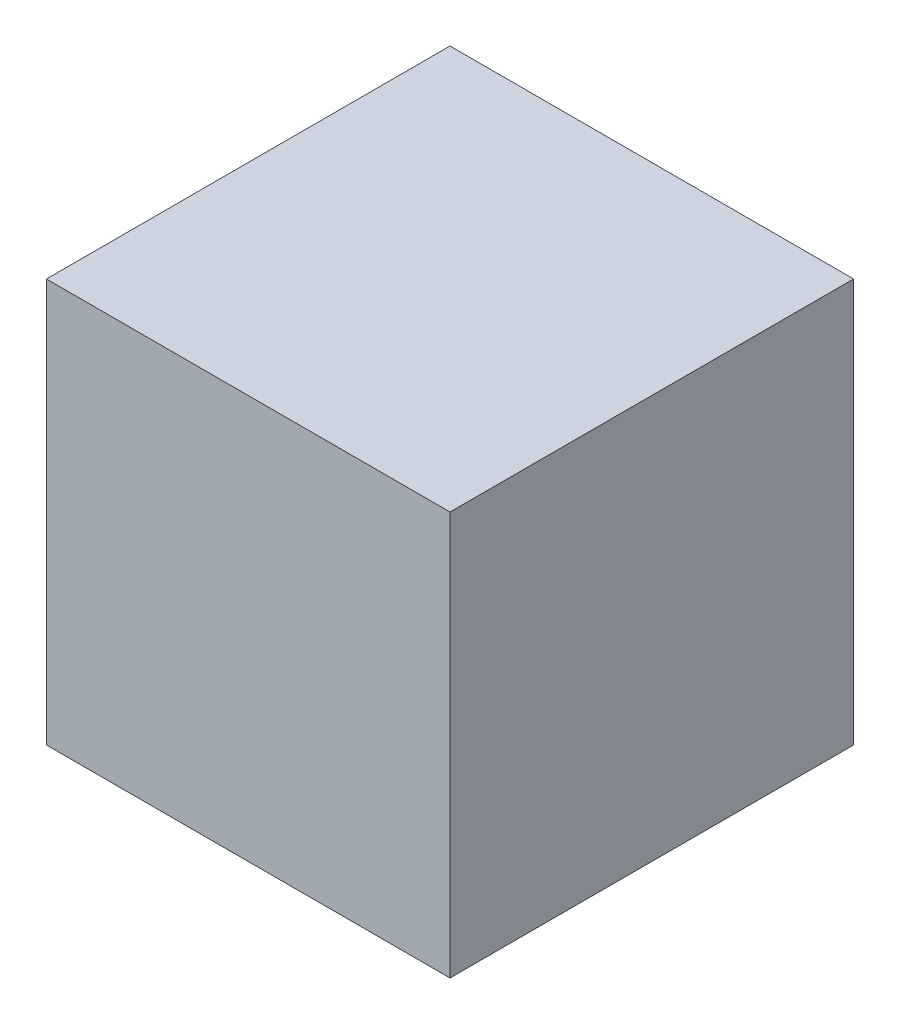
from build123d import *

# Parameters (mm, degrees)
SKETCH4_W           = 61
SKETCH4_H           = 61
BOSS_EXTRUDE4_DEPTH = 61


with BuildPart() as part:
    # Sketch4 → Boss-Extrude4 (new body)
    with BuildSketch(Plane.XY):
        Rectangle(SKETCH4_W, SKETCH4_H)
    extrude(amount=BOSS_EXTRUDE4_DEPTH)


solid = part.part
